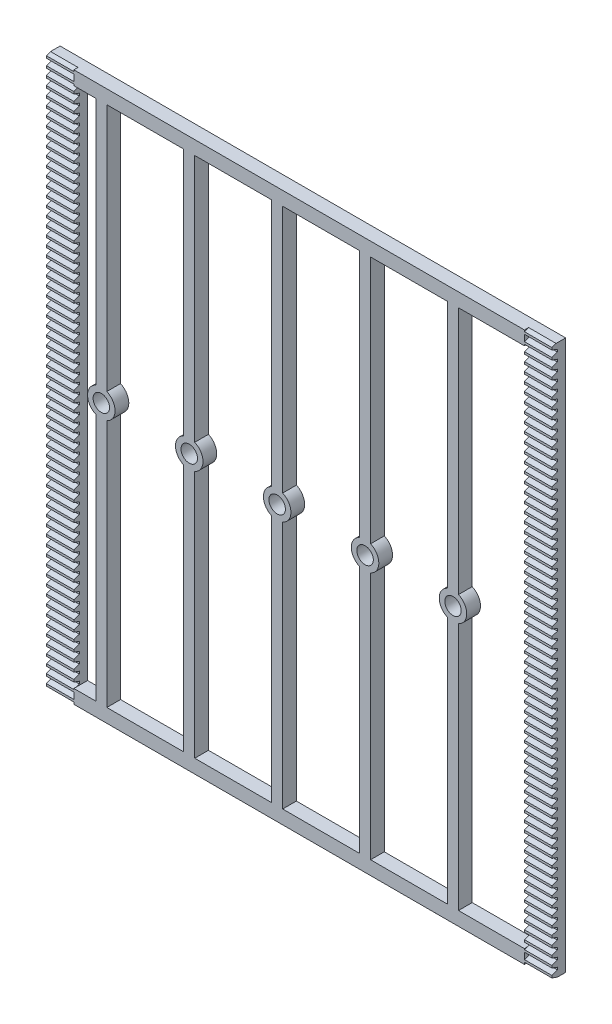
from build123d import *

# Parameters (mm, degrees)
SKETCH1_W           = 184
SKETCH1_H           = 200
BOSS_EXTRUDE1_DEPTH = 5
SKETCH2_W           = 164
SKETCH2_H           = 190
CUT_EXTRUDE1_DEPTH  = 5
BOSS_EXTRUDE2_DEPTH = 5
SKETCH4_R           = 3
CUT_EXTRUDE2_DEPTH  = 6
CUT_EXTRUDE3_DEPTH  = 10
LPATTERN3_COUNT     = 64
LPATTERN3_PITCH     = 3.14159
CUT_EXTRUDE4_DEPTH  = 10
LPATTERN4_COUNT     = 64
LPATTERN4_PITCH     = 3.14159
LPATTERN5_COUNT     = 5
LPATTERN5_PITCH     = 32


with BuildPart() as part:
    # Sketch1 → Boss-Extrude1 (new body)
    with BuildSketch(Plane.XY):
        Rectangle(SKETCH1_W, SKETCH1_H)
    extrude(amount=BOSS_EXTRUDE1_DEPTH)

    # Sketch2 → Cut-Extrude1 (cut)
    with BuildSketch(Plane.XY.offset(5)):
        Rectangle(SKETCH2_W, SKETCH2_H)
    extrude(amount=-CUT_EXTRUDE1_DEPTH, mode=Mode.SUBTRACT)

    # Sketch3 → Boss-Extrude2 (add)
    with BuildSketch(Plane.XY):
        with BuildLine():
            Line((-74, -95), (-74, -4.582575695))
            ThreePointArc((-74, -4.582575695), (-77, 0), (-74, 4.582575695))
            Line((-74, 4.582575695), (-74, 95))
            Line((-74, 95), (-70, 95))
            Line((-70, 95), (-70, 4.582575695))
            ThreePointArc((-70, 4.582575695), (-67, 0), (-70, -4.582575695))
            Line((-70, -4.582575695), (-70, -95))
            Line((-70, -95), (-74, -95))
        make_face()
    boss_extrude2 = extrude(amount=BOSS_EXTRUDE2_DEPTH)

    # Sketch4 → Cut-Extrude2 (cut, through all)
    with BuildSketch(Plane.XY.offset(5)):
        with Locations((-72, 0)):
            Circle(SKETCH4_R)
    cut_extrude2 = extrude(amount=-CUT_EXTRUDE2_DEPTH, mode=Mode.SUBTRACT)

    # Sketch5 → Cut-Extrude3 (cut)
    with BuildSketch(Plane(origin=(92, 0, 0), x_dir=(0, 0, -1), z_dir=(1, 0, 0))):
        Polygon((-5, -100), (-3, -100), (-5, -99.272059531), align=None)
        Polygon((-5, -98.472059531), (-3, -97.744119063), (-3, -96.85841), (-5, -96.85841), align=None)
    cut_extrude3 = extrude(amount=-CUT_EXTRUDE3_DEPTH, mode=Mode.SUBTRACT)

    # LPattern3: Cut-Extrude3 ×64
    with Locations(*[(0, i * LPATTERN3_PITCH, 0) for i in range(1, LPATTERN3_COUNT)]):
        add(cut_extrude3, mode=Mode.SUBTRACT)

    # Sketch6 → Cut-Extrude4 (cut)
    with BuildSketch(Plane.ZY.offset(92)):
        Polygon((5, -99.272059531), (3, -100), (5, -100), align=None)
        Polygon((3, -96.85841), (3, -97.744119063), (5, -98.472059531), (5, -96.85841), align=None)
    cut_extrude4 = extrude(amount=-CUT_EXTRUDE4_DEPTH, mode=Mode.SUBTRACT)

    # LPattern4: Cut-Extrude4 ×64
    with Locations(*[(0, i * LPATTERN4_PITCH, 0) for i in range(1, LPATTERN4_COUNT)]):
        add(cut_extrude4, mode=Mode.SUBTRACT)

    # LPattern5: Boss-Extrude2, Cut-Extrude2 ×5
    with Locations(*[(i * LPATTERN5_PITCH, 0, 0) for i in range(1, LPATTERN5_COUNT)]):
        add(boss_extrude2)
        add(cut_extrude2, mode=Mode.SUBTRACT)


solid = part.part
